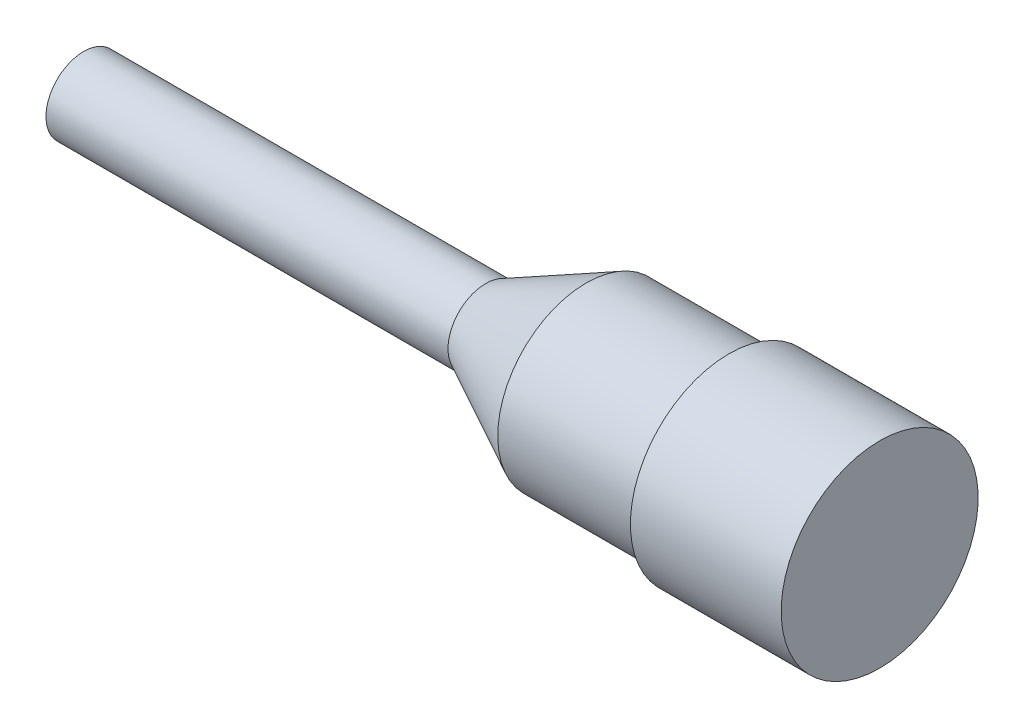
from build123d import *


with BuildPart() as part:
    # Sketch1 → Revolve1 (revolve)
    with BuildSketch(Plane.XY):
        Polygon((0, 0), (-100.584, 0), (-100.584, 4.7625), (-49.784, 4.7625), (-37.084, 11.176), (-19.05, 11.176), (-19.05, 12.446), (0, 12.446), align=None)
    revolve(axis=Axis((0, 0, 0), (-1, 0, 0)))


solid = part.part
